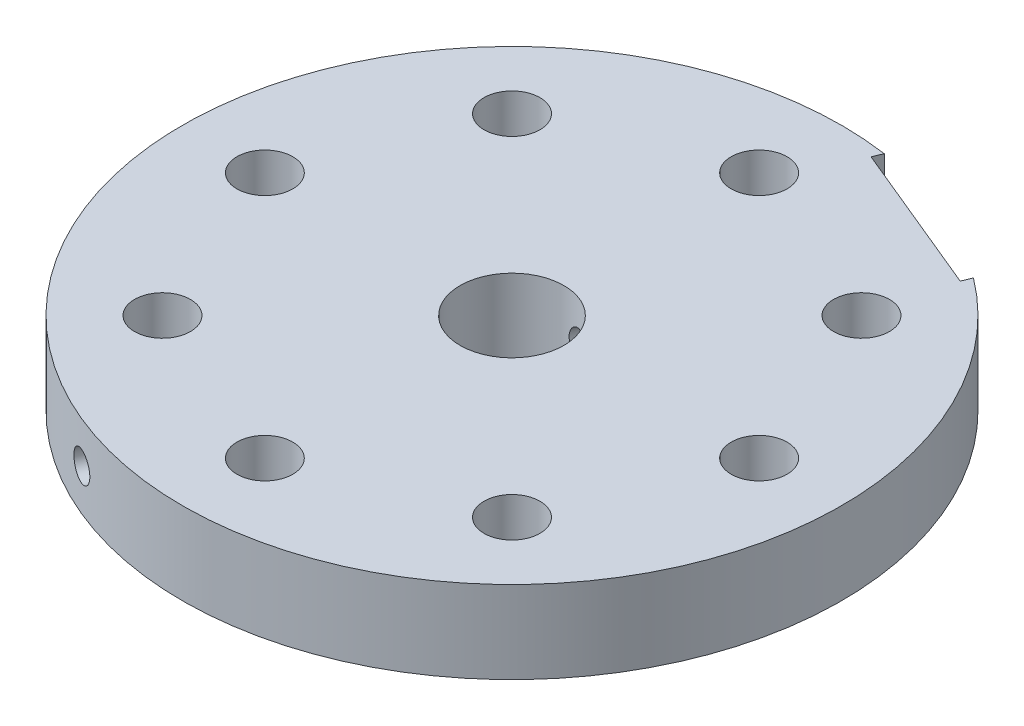
from build123d import *

# Parameters (mm, degrees)
SKETCH1_R              = 25.4
BOSS_EXTRUDE1_DEPTH    = 6.35
CUT_EXTRUDE2_REACH     = 8.35
SKETCH3_R              = 2.15265
SKETCH5_W              = 12.7
SKETCH5_H              = 6.35
CUT_EXTRUDE3_DEPTH     = 1.5875
F_4_40TAPPEDHOLE_REACH = 58.999
SKETCH6_R              = 1.1303
CUT_EXTRUDE5_REACH     = 8.35
SKETCH8_R              = 4


with BuildPart() as part:
    # Sketch1 → Boss-Extrude1 (new body)
    with BuildSketch(Plane(origin=(0, 0, 0), x_dir=(1, 0, 0), z_dir=(0, 1, 0))):
        Circle(SKETCH1_R)
    extrude(amount=BOSS_EXTRUDE1_DEPTH)

    # Sketch3 → Cut-Extrude2 (cut, up to next)
    with BuildSketch(Plane(origin=(0, 6.35, 0), x_dir=(1, 0, 0), z_dir=(0, 1, 0)), mode=Mode.PRIVATE) as cut_extrude2_sk1:
        with Locations((-13.470384182, 13.470384182)):
            Circle(SKETCH3_R)
    cut_extrude2_tool1 = extrude(cut_extrude2_sk1.sketch, amount=-CUT_EXTRUDE2_REACH, mode=Mode.PRIVATE) & part.part
    add(cut_extrude2_tool1.solids().sort_by_distance((-13.470384, 6.35, -13.470384))[0], mode=Mode.SUBTRACT)
    # Sketch3 → Cut-Extrude2 (cut, up to next)
    with BuildSketch(Plane(origin=(0, 6.35, 0), x_dir=(1, 0, 0), z_dir=(0, 1, 0)), mode=Mode.PRIVATE) as cut_extrude2_sk2:
        with Locations((0, 19.05)):
            Circle(SKETCH3_R)
    cut_extrude2_tool2 = extrude(cut_extrude2_sk2.sketch, amount=-CUT_EXTRUDE2_REACH, mode=Mode.PRIVATE) & part.part
    add(cut_extrude2_tool2.solids().sort_by_distance((0, 6.35, -19.05))[0], mode=Mode.SUBTRACT)
    # Sketch3 → Cut-Extrude2 (cut, up to next)
    with BuildSketch(Plane(origin=(0, 6.35, 0), x_dir=(1, 0, 0), z_dir=(0, 1, 0)), mode=Mode.PRIVATE) as cut_extrude2_sk3:
        with Locations((13.470384182, 13.470384182)):
            Circle(SKETCH3_R)
    cut_extrude2_tool3 = extrude(cut_extrude2_sk3.sketch, amount=-CUT_EXTRUDE2_REACH, mode=Mode.PRIVATE) & part.part
    add(cut_extrude2_tool3.solids().sort_by_distance((13.470384, 6.35, -13.470384))[0], mode=Mode.SUBTRACT)
    # Sketch3 → Cut-Extrude2 (cut, up to next)
    with BuildSketch(Plane(origin=(0, 6.35, 0), x_dir=(1, 0, 0), z_dir=(0, 1, 0)), mode=Mode.PRIVATE) as cut_extrude2_sk4:
        with Locations((19.05, 0)):
            Circle(SKETCH3_R)
    cut_extrude2_tool4 = extrude(cut_extrude2_sk4.sketch, amount=-CUT_EXTRUDE2_REACH, mode=Mode.PRIVATE) & part.part
    add(cut_extrude2_tool4.solids().sort_by_distance((19.05, 6.35, 0))[0], mode=Mode.SUBTRACT)
    # Sketch3 → Cut-Extrude2 (cut, up to next)
    with BuildSketch(Plane(origin=(0, 6.35, 0), x_dir=(1, 0, 0), z_dir=(0, 1, 0)), mode=Mode.PRIVATE) as cut_extrude2_sk5:
        with Locations((13.470384182, -13.470384182)):
            Circle(SKETCH3_R)
    cut_extrude2_tool5 = extrude(cut_extrude2_sk5.sketch, amount=-CUT_EXTRUDE2_REACH, mode=Mode.PRIVATE) & part.part
    add(cut_extrude2_tool5.solids().sort_by_distance((13.470384, 6.35, 13.470384))[0], mode=Mode.SUBTRACT)
    # Sketch3 → Cut-Extrude2 (cut, up to next)
    with BuildSketch(Plane(origin=(0, 6.35, 0), x_dir=(1, 0, 0), z_dir=(0, 1, 0)), mode=Mode.PRIVATE) as cut_extrude2_sk6:
        with Locations((0, -19.05)):
            Circle(SKETCH3_R)
    cut_extrude2_tool6 = extrude(cut_extrude2_sk6.sketch, amount=-CUT_EXTRUDE2_REACH, mode=Mode.PRIVATE) & part.part
    add(cut_extrude2_tool6.solids().sort_by_distance((0, 6.35, 19.05))[0], mode=Mode.SUBTRACT)
    # Sketch3 → Cut-Extrude2 (cut, up to next)
    with BuildSketch(Plane(origin=(0, 6.35, 0), x_dir=(1, 0, 0), z_dir=(0, 1, 0)), mode=Mode.PRIVATE) as cut_extrude2_sk7:
        with Locations((-13.470384182, -13.470384182)):
            Circle(SKETCH3_R)
    cut_extrude2_tool7 = extrude(cut_extrude2_sk7.sketch, amount=-CUT_EXTRUDE2_REACH, mode=Mode.PRIVATE) & part.part
    add(cut_extrude2_tool7.solids().sort_by_distance((-13.470384, 6.35, 13.470384))[0], mode=Mode.SUBTRACT)
    # Sketch3 → Cut-Extrude2 (cut, up to next)
    with BuildSketch(Plane(origin=(0, 6.35, 0), x_dir=(1, 0, 0), z_dir=(0, 1, 0)), mode=Mode.PRIVATE) as cut_extrude2_sk8:
        with Locations((-19.05, 0)):
            Circle(SKETCH3_R)
    cut_extrude2_tool8 = extrude(cut_extrude2_sk8.sketch, amount=-CUT_EXTRUDE2_REACH, mode=Mode.PRIVATE) & part.part
    add(cut_extrude2_tool8.solids().sort_by_distance((-19.05, 6.35, 0))[0], mode=Mode.SUBTRACT)

    # Sketch5 → Cut-Extrude3 (cut)
    with BuildSketch(Plane(origin=(9.720159182, 0, -23.466540126), x_dir=(-0.923879533, 0, -0.382683432), z_dir=(0.382683432, 0, -0.923879533))):
        with Locations((0, 3.175)):
            Rectangle(SKETCH5_W, SKETCH5_H)
    extrude(amount=-CUT_EXTRUDE3_DEPTH, mode=Mode.SUBTRACT)

    # Sketch6 → 4-40TappedHole (cut, up to next)
    with BuildSketch(Plane(origin=(9.112649233, 0, -21.999881368), x_dir=(-0.923879533, 0, -0.382683432), z_dir=(0.382683432, 0, -0.923879533)), mode=Mode.PRIVATE) as f_4_40tappedhole_sk1:
        with Locations((0, 3.175)):
            Circle(SKETCH6_R)
    f_4_40tappedhole_tool1 = extrude(f_4_40tappedhole_sk1.sketch, amount=-F_4_40TAPPEDHOLE_REACH, mode=Mode.PRIVATE) & part.part
    add(f_4_40tappedhole_tool1.solids().sort_by_distance((9.112649, 3.175, -21.999881))[0], mode=Mode.SUBTRACT)

    # Sketch8 → Cut-Extrude5 (cut, up to next)
    with BuildSketch(Plane(origin=(0, 6.35, 0), x_dir=(1, 0, 0), z_dir=(0, 1, 0)), mode=Mode.PRIVATE) as cut_extrude5_sk1:
        Circle(SKETCH8_R)
    cut_extrude5_tool1 = extrude(cut_extrude5_sk1.sketch, amount=-CUT_EXTRUDE5_REACH, mode=Mode.PRIVATE) & part.part
    add(cut_extrude5_tool1.solids().sort_by_distance((0, 6.35, 0))[0], mode=Mode.SUBTRACT)


solid = part.part
